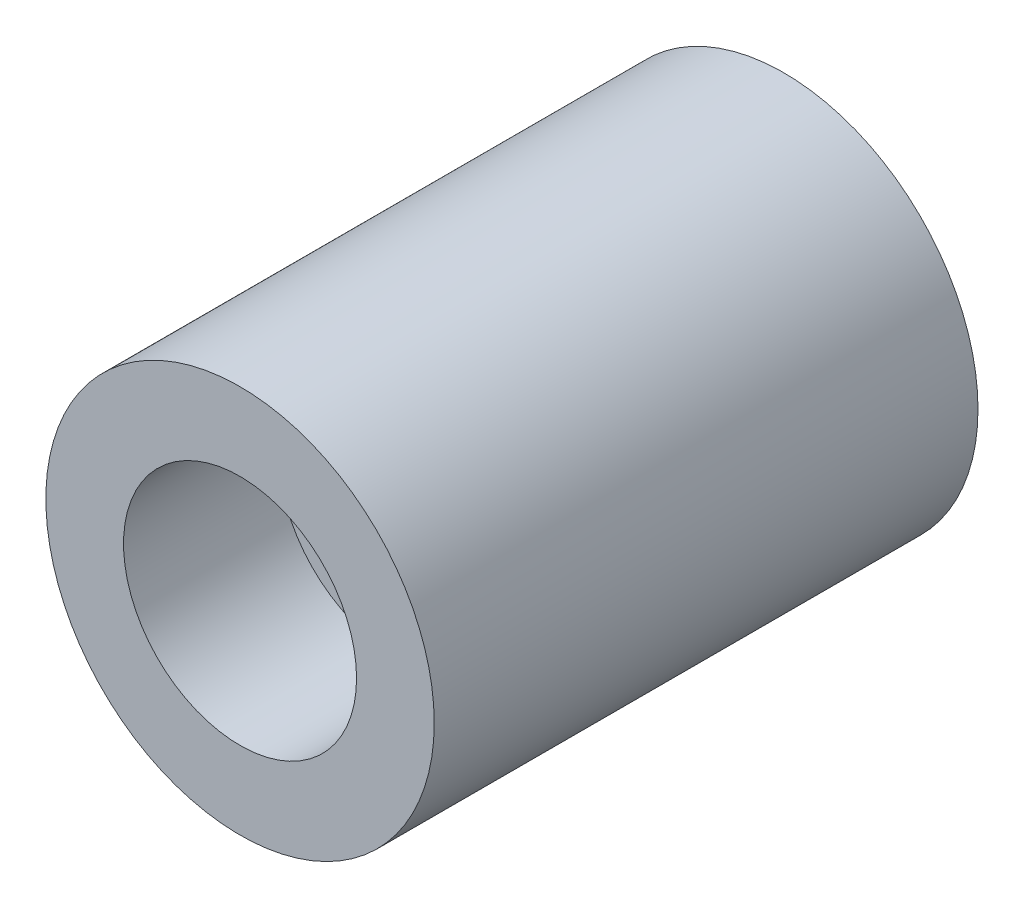
from build123d import *

# Parameters (mm, degrees)
SKETCH1_R           = 1270
BOSS_EXTRUDE1_DEPTH = 3556
SKETCH2_R           = 762
CUT_EXTRUDE1_DEPTH  = 1016
SKETCH3_R           = 254
CUT_EXTRUDE2_DEPTH  = 3048


with BuildPart() as part:
    # Sketch1 → Boss-Extrude1 (new body)
    with BuildSketch(Plane.XY):
        Circle(SKETCH1_R)
    extrude(amount=BOSS_EXTRUDE1_DEPTH)

    # Sketch2 → Cut-Extrude1 (cut)
    with BuildSketch(Plane.XY.offset(3556)):
        Circle(SKETCH2_R)
    extrude(amount=-CUT_EXTRUDE1_DEPTH, mode=Mode.SUBTRACT)

    # Sketch3 → Cut-Extrude2 (cut)
    with BuildSketch(Plane.XY.offset(3556)):
        Circle(SKETCH3_R)
    extrude(amount=-CUT_EXTRUDE2_DEPTH, mode=Mode.SUBTRACT)


solid = part.part
